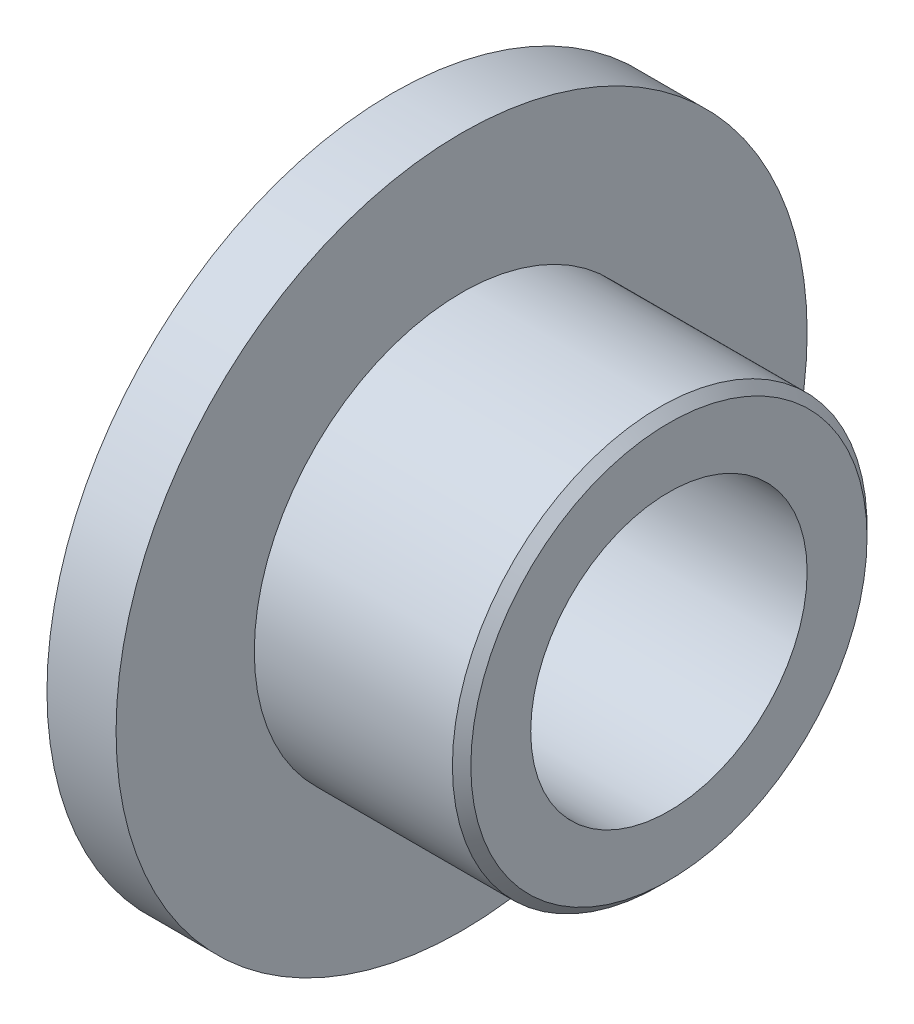
from build123d import *


with BuildPart() as part:
    # 草图1 → 旋转1 (revolve)
    with BuildSketch(Plane(origin=(0, 0, 0), x_dir=(-1, 0, 0), z_dir=(0, 0, -1))):
        Polygon((0, 3.75), (-0.75, 3.75), (-0.75, 2.25), (-2.9, 2.25), (-3, 2.15), (-3, 1.5), (0, 1.5), align=None)
    revolve(axis=Axis((4, 0, 0), (-1, 0, 0)))


solid = part.part
